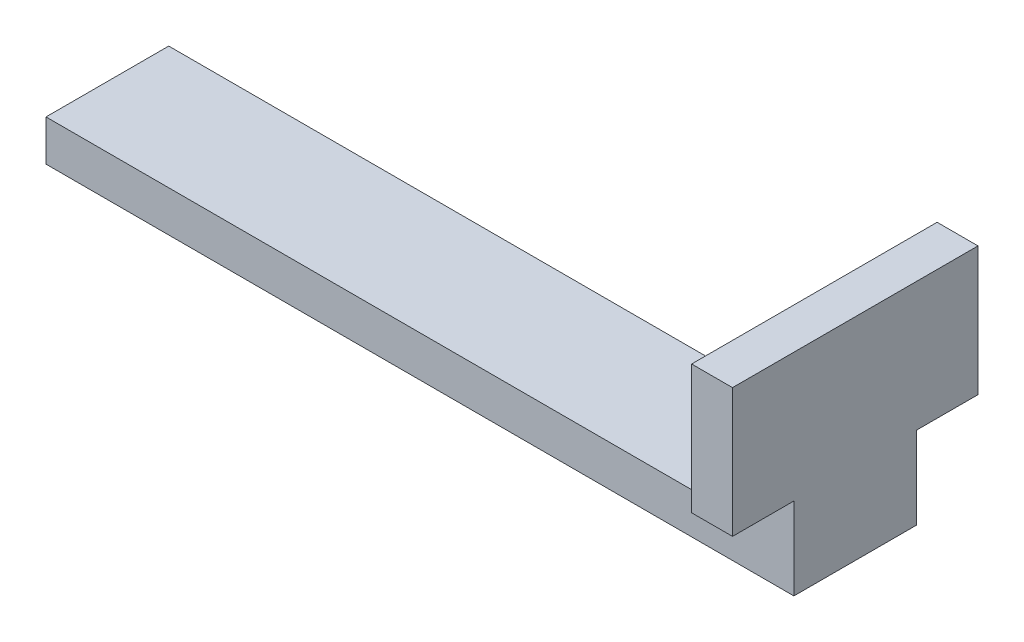
from build123d import *

# Parameters (mm, degrees)
BOSS_EXTRUDE1_DEPTH = 9.525
SKETCH3_W           = 38.1
SKETCH3_H           = 20
BOSS_EXTRUDE2_DEPTH = 6.35


with BuildPart() as part:
    # Sketch2 → Boss-Extrude1 (new body, symmetric)
    with BuildSketch(Plane.XY):
        Polygon((-109.728, 0), (0, 0), (6.35, 0), (6.35, 32.766), (0, 32.766), (0, 6.35), (-109.728, 6.35), align=None)
    extrude(amount=BOSS_EXTRUDE1_DEPTH, both=True)

    # Sketch3 → Boss-Extrude2 (add)
    with BuildSketch(Plane.ZY):
        with Locations((0, 22.766)):
            Rectangle(SKETCH3_W, SKETCH3_H)
    extrude(amount=-BOSS_EXTRUDE2_DEPTH)


solid = part.part
